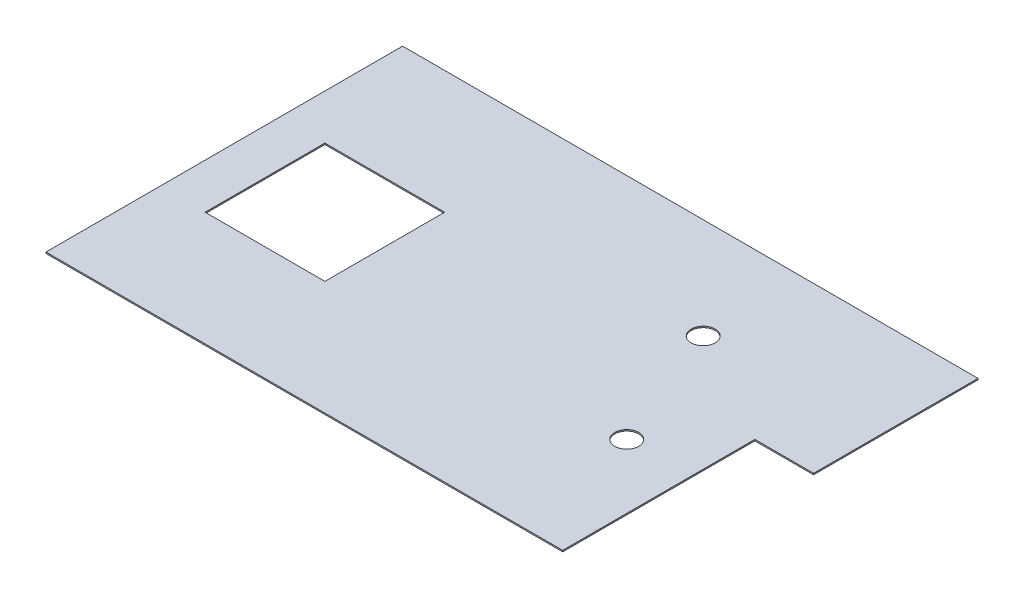
from build123d import *

# Parameters (mm, degrees)
SKETCH1_R           = 57.15
SKETCH1_W           = 569.976
SKETCH1_H           = 569.976
BOSS_EXTRUDE1_DEPTH = 6.35


with BuildPart() as part:
    # Sketch1 → Boss-Extrude1 (new body)
    with BuildSketch(Plane(origin=(0, 0, 0), x_dir=(1, 0, 0), z_dir=(0, 1, 0))):
        Polygon((1369.06, 66.04), (1089.66, 66.04), (1089.66, -848.36), (-1369.06, -848.36), (-1369.06, 848.36), (1369.06, 848.36), align=None)
        with Locations((540.512, 369.316)):
            Circle(SKETCH1_R, mode=Mode.SUBTRACT)
        with Locations((784.86, -238.76)):
            Circle(SKETCH1_R, mode=Mode.SUBTRACT)
        with Locations((-869.442, -20.828)):
            Rectangle(SKETCH1_W, SKETCH1_H, mode=Mode.SUBTRACT)
    extrude(amount=BOSS_EXTRUDE1_DEPTH)


solid = part.part
